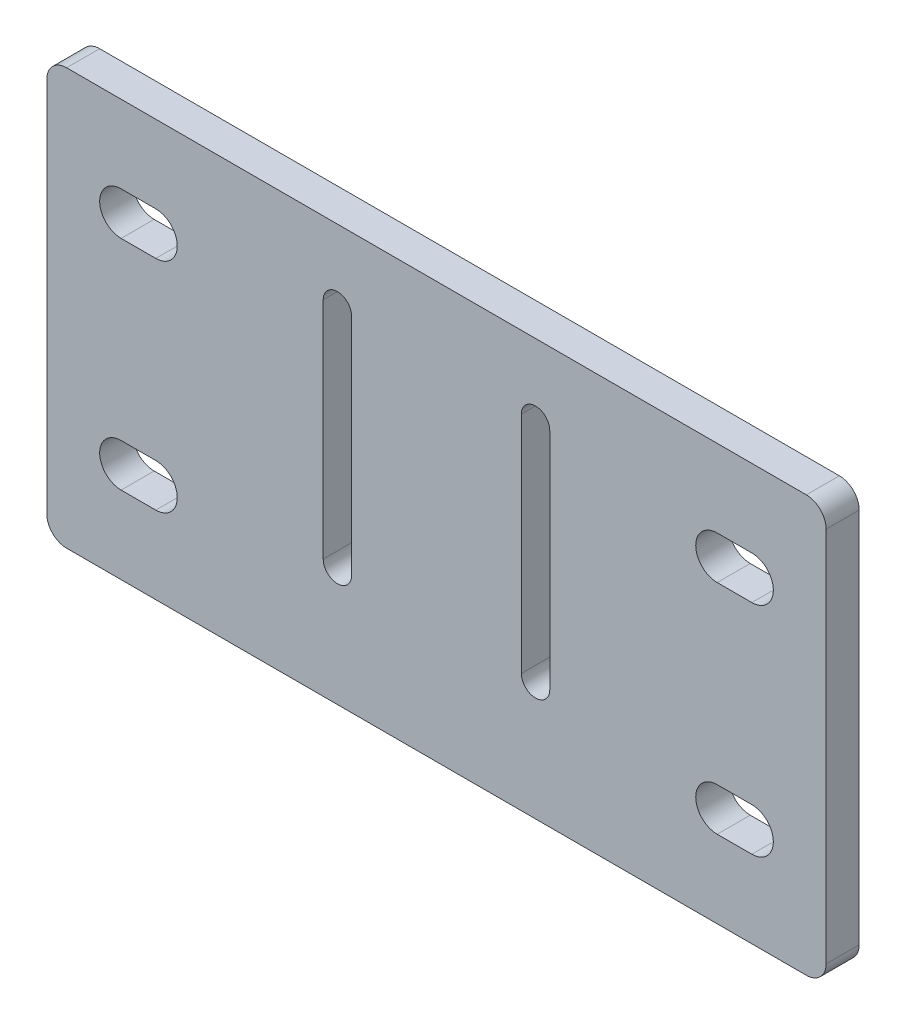
from build123d import *

# Parameters (mm, degrees)
EXTRUDE_1_DEPTH     = 5
CUT_EXTRUDE_1_DEPTH = 10


with BuildPart() as part:
    # 草图1 → 凸台-拉伸1 (new body)
    with BuildSketch(Plane.XY):
        with BuildLine():
            Line((-59, -25), (-59, -32))
            ThreePointArc((-59, -32), (-58.121320344, -34.121320344), (-56, -35))
            Line((-56, -35), (56, -35))
            ThreePointArc((56, -35), (58.121320344, -34.121320344), (59, -32))
            Line((59, -32), (59, -25))
            Line((59, -25), (59, 25))
            ThreePointArc((59, 25), (58.121320344, 27.121320344), (56, 28))
            Line((56, 28), (-56, 28))
            ThreePointArc((-56, 28), (-58.121320344, 27.121320344), (-59, 25))
            Line((-59, 25), (-59, -25))
        make_face()
        with BuildLine():
            Line((12.85, -17), (12.85, 17))
            ThreePointArc((12.85, 17), (15, 19.15), (17.15, 17))
            Line((17.15, 17), (17.15, -17))
            ThreePointArc((17.15, -17), (15, -19.15), (12.85, -17))
        make_face(mode=Mode.SUBTRACT)
        with BuildLine():
            Line((-12.85, -17), (-12.85, 17))
            ThreePointArc((-12.85, 17), (-15, 19.15), (-17.15, 17))
            Line((-17.15, 17), (-17.15, -17))
            ThreePointArc((-17.15, -17), (-15, -19.15), (-12.85, -17))
        make_face(mode=Mode.SUBTRACT)
    extrude(amount=EXTRUDE_1_DEPTH)

    # 草图2 → 切除-拉伸1 (cut)
    with BuildSketch(Plane.XY.offset(5)):
        with BuildLine():
            Line((-47.75, 16.25), (-42.5, 16.25))
            ThreePointArc((-42.5, 16.25), (-39.25, 13), (-42.5, 9.75))
            Line((-42.5, 9.75), (-47.75, 9.75))
            ThreePointArc((-47.75, 9.75), (-51, 13), (-47.75, 16.25))
        make_face()
        with BuildLine():
            Line((-47.75, -23.25), (-42.5, -23.25))
            ThreePointArc((-42.5, -23.25), (-39.25, -20), (-42.5, -16.75))
            Line((-42.5, -16.75), (-47.75, -16.75))
            ThreePointArc((-47.75, -16.75), (-51, -20), (-47.75, -23.25))
        make_face()
        with BuildLine():
            Line((47.75, 16.25), (42.5, 16.25))
            ThreePointArc((42.5, 16.25), (39.25, 13), (42.5, 9.75))
            Line((42.5, 9.75), (47.75, 9.75))
            ThreePointArc((47.75, 9.75), (51, 13), (47.75, 16.25))
        make_face()
        with BuildLine():
            Line((47.75, -23.25), (42.5, -23.25))
            ThreePointArc((42.5, -23.25), (39.25, -20), (42.5, -16.75))
            Line((42.5, -16.75), (47.75, -16.75))
            ThreePointArc((47.75, -16.75), (51, -20), (47.75, -23.25))
        make_face()
    extrude(amount=-CUT_EXTRUDE_1_DEPTH, mode=Mode.SUBTRACT)


solid = part.part
